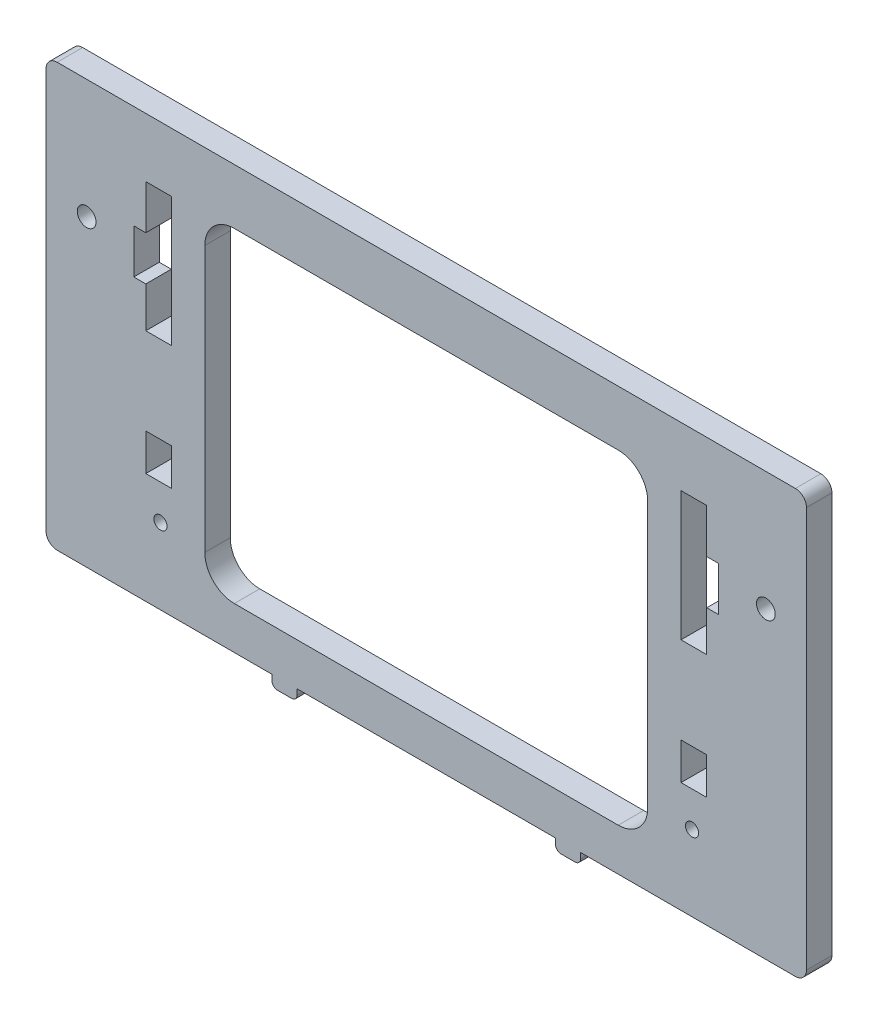
from build123d import *

# Parameters (mm, degrees)
SKETCH1_W           = 206
SKETCH1_H           = 114.5
BOSS_EXTRUDE1_DEPTH = 6.9
SKETCH2_W           = 120
SKETCH2_H           = 88
CUT_EXTRUDE1_DEPTH  = 7.9
FILLET1_R           = 8
SKETCH7_R           = 2.54
CUT_EXTRUDE5_DEPTH  = 7.9
SKETCH9_W           = 6.96
SKETCH9_H           = 35
SKETCH9_H_2         = 10
CUT_EXTRUDE7_DEPTH  = 7.9
SKETCH11_W          = 3.25
SKETCH11_H          = 12
CUT_EXTRUDE8_DEPTH  = 7.9
FILLET2_R           = 3
SKETCH8_R           = 1.775
CUT_EXTRUDE6_DEPTH  = 7.9
SKETCH10_W          = 6.8
SKETCH10_H          = 3
BOSS_EXTRUDE3_DEPTH = 6.9
FILLET3_R           = 1.5


with BuildPart() as part:
    # Sketch1 → Boss-Extrude1 (new body)
    with BuildSketch(Plane.XY):
        Rectangle(SKETCH1_W, SKETCH1_H)
    extrude(amount=-BOSS_EXTRUDE1_DEPTH)

    # Sketch2 → Cut-Extrude1 (cut, through all)
    with BuildSketch(Plane.XY):
        with Locations((0, -1.75)):
            Rectangle(SKETCH2_W, SKETCH2_H)
    extrude(amount=-CUT_EXTRUDE1_DEPTH, mode=Mode.SUBTRACT)

    # Fillet1
    fillet1_edges = [part.edges().sort_by_distance(p)[0] for p in [
        (-60, -45.75, -3.45),
        (-60, 42.25, -3.45),
        (60, 42.25, -3.45),
        (60, -45.75, -3.45),
    ]]
    fillet(fillet1_edges, radius=FILLET1_R)

    # Sketch7 → Cut-Extrude5 (cut, through all)
    with BuildSketch(Plane.XY):
        with Locations((-92, 25)):
            Circle(SKETCH7_R)
    cut_extrude5 = extrude(amount=-CUT_EXTRUDE5_DEPTH, mode=Mode.SUBTRACT)

    # Sketch9 → Cut-Extrude7 (cut, through all)
    with BuildSketch(Plane.XY):
        with Locations((-72.5, 23.75)):
            Rectangle(SKETCH9_W, SKETCH9_H)
        with Locations((-72.5, -22.25)):
            Rectangle(SKETCH9_W, SKETCH9_H_2)
    cut_extrude7 = extrude(amount=-CUT_EXTRUDE7_DEPTH, mode=Mode.SUBTRACT)

    # Sketch11 → Cut-Extrude8 (cut, through all)
    with BuildSketch(Plane.XY):
        with Locations((-77.605, 23.25)):
            Rectangle(SKETCH11_W, SKETCH11_H)
    cut_extrude8 = extrude(amount=-CUT_EXTRUDE8_DEPTH, mode=Mode.SUBTRACT)

    # Mirror2: Cut-Extrude5, Cut-Extrude7, Cut-Extrude8 across plane
    add(cut_extrude5.mirror(Plane(origin=(0, 0, 0), x_dir=(0, 0, 1), z_dir=(1, 0, 0))), mode=Mode.SUBTRACT)
    add(cut_extrude7.mirror(Plane(origin=(0, 0, 0), x_dir=(0, 0, 1), z_dir=(1, 0, 0))), mode=Mode.SUBTRACT)
    add(cut_extrude8.mirror(Plane(origin=(0, 0, 0), x_dir=(0, 0, 1), z_dir=(1, 0, 0))), mode=Mode.SUBTRACT)

    # Fillet2
    fillet2_edges = [part.edges().sort_by_distance(p)[0] for p in [
        (-103, 57.25, -3.45),
        (103, 57.25, -3.45),
        (103, -57.25, -3.45),
        (-103, -57.25, -3.45),
    ]]
    fillet(fillet2_edges, radius=FILLET2_R)

    # Sketch8 → Cut-Extrude6 (cut, through all)
    with BuildSketch(Plane.XY):
        with Locations((72, -36.75)):
            Circle(SKETCH8_R)
        with Locations((-72, -36.75)):
            Circle(SKETCH8_R)
    extrude(amount=-CUT_EXTRUDE6_DEPTH, mode=Mode.SUBTRACT)

    # Sketch10 → Boss-Extrude3 (add)
    with BuildSketch(Plane.XY):
        with Locations((-38.4, -58.75)):
            Rectangle(SKETCH10_W, SKETCH10_H)
        with Locations((38.4, -58.75)):
            Rectangle(SKETCH10_W, SKETCH10_H)
    extrude(amount=-BOSS_EXTRUDE3_DEPTH)

    # Fillet3
    fillet3_edges = [part.edges().sort_by_distance(p)[0] for p in [
        (-35, -60.25, -3.45),
        (-41.8, -60.25, -3.45),
        (35, -60.25, -3.45),
        (41.8, -60.25, -3.45),
    ]]
    fillet(fillet3_edges, radius=FILLET3_R)


solid = part.part
